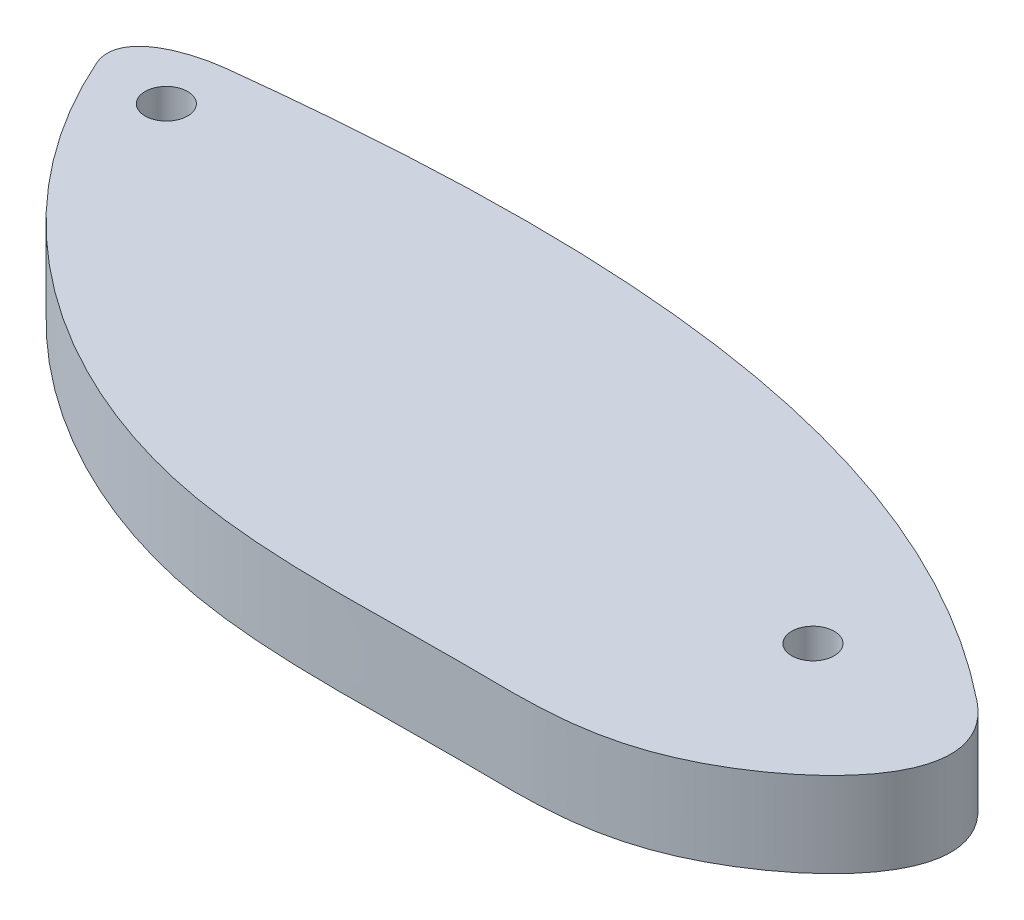
from build123d import *

# Parameters (mm, degrees)
SKETCH1_R           = 0.79375
BOSS_EXTRUDE1_DEPTH = 3.175


with BuildPart() as part:
    # Sketch1 → Boss-Extrude1 (new body)
    with BuildSketch(Plane(origin=(0, 0, 0), x_dir=(1, 0, 0), z_dir=(0, 1, 0))):
        with BuildLine():
            add(Edge.make_bspline(
                [(49.412189484, 14.443157545), (50.761648696, 11.392855179), (55.172987066, 5.915157755), (64.97864162, 1.398978829), (75.147185312, 2.089733415), (83.105841305, 1.55391046), (89.416410621, 7.888590669), (86.463066332, 10.256559663)],
                knots=[0, 0, 0, 0, 0.211071899, 0.438109061, 0.667266743, 0.84075123, 1, 1, 1, 1], degree=3))
            add(Edge.make_bspline(
                [(86.463066332, 10.256559663), (83.212986527, 12.862448937), (73.898782123, 17.329617093), (61.577330311, 17.655900513), (53.645408959, 16.888370063), (52.023242095, 16.703785699)],
                knots=[0, 0, 0, 0, 0.334481553, 0.861935931, 1, 1, 1, 1], degree=3))
            add(Edge.make_bspline(
                [(49.412189484, 14.443157545), (48.799547338, 15.827966933), (50.600615633, 16.541906791), (52.023242095, 16.703785699)],
                knots=[0, 0, 0, 0, 1, 1, 1, 1], degree=3))
        make_face()
        with Locations((52.023242095, 14.443157545)):
            Circle(SKETCH1_R, mode=Mode.SUBTRACT)
        with Locations((81.533232746, 9.062953732)):
            Circle(SKETCH1_R, mode=Mode.SUBTRACT)
    extrude(amount=BOSS_EXTRUDE1_DEPTH)


solid = part.part
